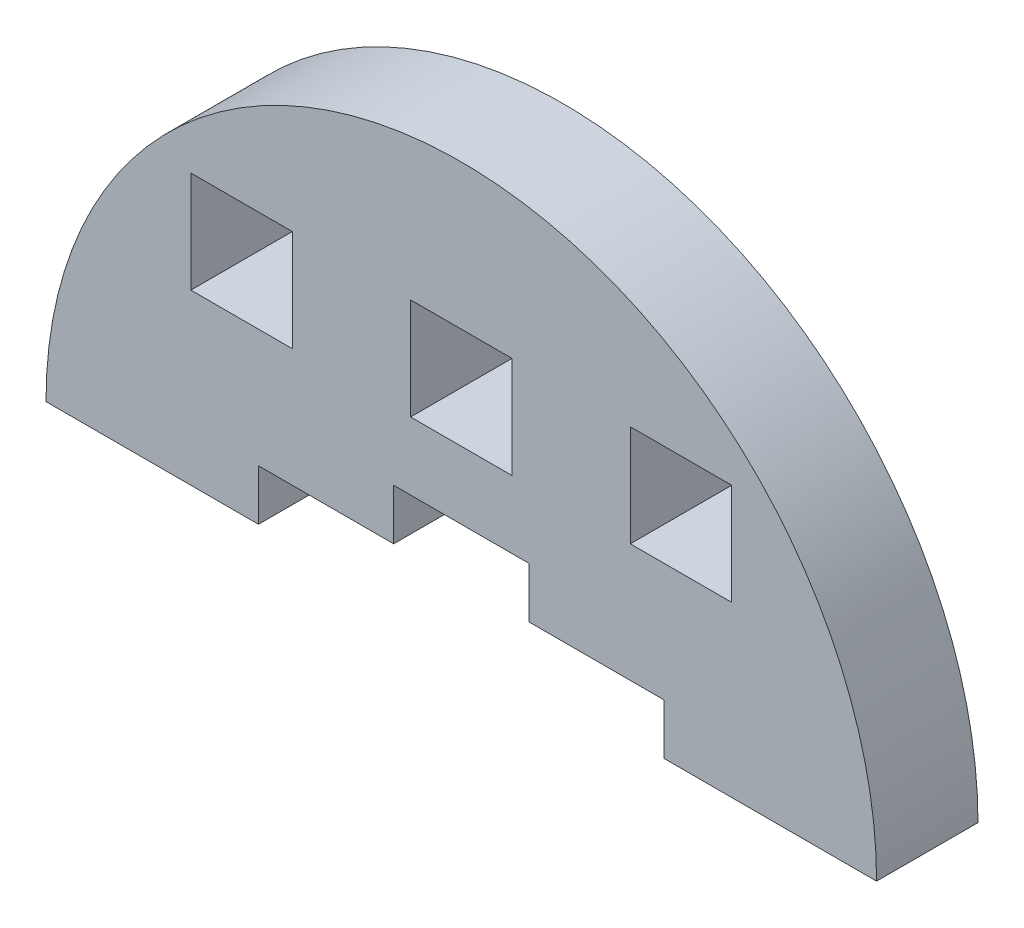
from build123d import *

# Parameters (mm, degrees)
MODEL_W             = 6
MODEL_H             = 6
BOSS_EXTRUDE1_DEPTH = 6


with BuildPart() as part:
    # Model → Boss-Extrude1 (new body)
    with BuildSketch(Plane.XY):
        with BuildLine():
            Line((3736.95412545, 1243.781770146), (3749.525554021, 1243.781770146))
            Line((3749.525554021, 1243.781770146), (3749.525554021, 1246.781770146))
            Line((3749.525554021, 1246.781770146), (3757.525554021, 1246.781770146))
            Line((3757.525554021, 1246.781770146), (3757.525554021, 1249.781770146))
            Line((3757.525554021, 1249.781770146), (3765.525554021, 1249.781770146))
            Line((3765.525554021, 1249.781770146), (3765.525554021, 1246.781770146))
            Line((3765.525554021, 1246.781770146), (3773.525554021, 1246.781770146))
            Line((3773.525554021, 1246.781770146), (3773.525554021, 1243.781770146))
            Line((3773.525554021, 1243.781770146), (3786.096982592, 1243.781770146))
            ThreePointArc((3786.096982592, 1243.781770146), (3761.525554021, 1268.353198718), (3736.95412545, 1243.781770146))
        make_face()
        with Locations((3774.525554021, 1256.781770147)):
            Rectangle(MODEL_W, MODEL_H, mode=Mode.SUBTRACT)
        with Locations((3748.525554021, 1256.781770147)):
            Rectangle(MODEL_W, MODEL_H, mode=Mode.SUBTRACT)
        with Locations((3761.525554021, 1256.781770147)):
            Rectangle(MODEL_W, MODEL_H, mode=Mode.SUBTRACT)
    extrude(amount=BOSS_EXTRUDE1_DEPTH)


solid = part.part
